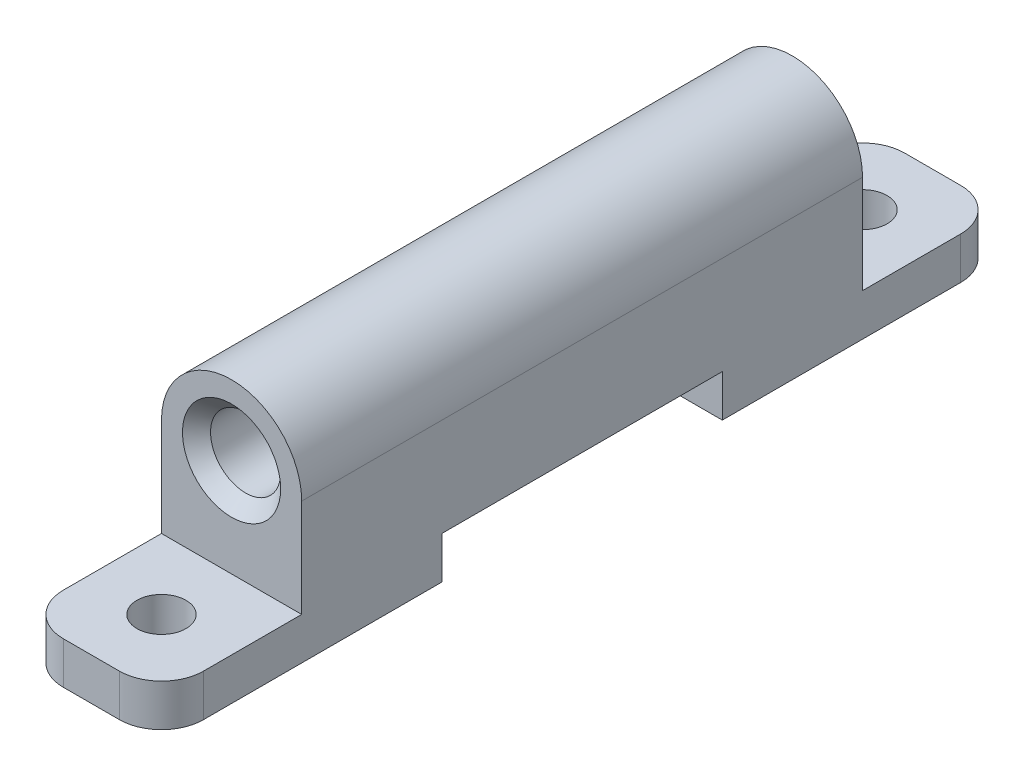
from build123d import *

# Parameters (mm, degrees)
SKETCH_1_R             = 2.5
EXTRUDE_1_DEPTH        = 20
SKETCH_2_W             = 10
SKETCH_2_H             = 20
EXTRUDE_2_DEPTH        = 3
SKETCH_3_R             = 1.75
CUT_EXTRUDE_1_DEPTH    = 4
FILLET_1_R             = 3
FILLET_1_OF_MIRROR_1_R = 3
CHAMFER_1_SIZE         = 1


with BuildPart() as part:
    # ｽｹｯﾁ1 → ﾎﾞｽ - 押し出し1 (new body, symmetric)
    with BuildSketch(Plane.XY):
        with BuildLine():
            Line((-5, 0), (5, 0))
            Line((5, 0), (5, 7))
            ThreePointArc((5, 7), (0, 12), (-5, 7))
            Line((-5, 7), (-5, 0))
        make_face()
        with Locations((0, 7)):
            Circle(SKETCH_1_R, mode=Mode.SUBTRACT)
    extrude(amount=EXTRUDE_1_DEPTH, both=True)

    # ｽｹｯﾁ2 → ﾎﾞｽ - 押し出し2 (add)
    with BuildSketch(Plane.XZ):
        with Locations((0, 20)):
            Rectangle(SKETCH_2_W, SKETCH_2_H)
    extrude_2 = extrude(amount=EXTRUDE_2_DEPTH)

    # ｽｹｯﾁ3 → ｶｯﾄ - 押し出し1 (cut, through all)
    with BuildSketch(Plane(origin=(0, 0, 0), x_dir=(1, 0, 0), z_dir=(0, 1, 0))):
        with Locations((0, -25)):
            Circle(SKETCH_3_R)
    cut_extrude_1 = extrude(amount=-CUT_EXTRUDE_1_DEPTH, mode=Mode.SUBTRACT)

    # ﾌｨﾚｯﾄ1
    fillet_1_edges = [part.edges().sort_by_distance(p)[0] for p in [
        (-5, -1.5, 30),
        (5, -1.5, 30),
    ]]
    fillet(fillet_1_edges, radius=FILLET_1_R)

    # ﾐﾗｰ1: ﾎﾞｽ - 押し出し2, ｶｯﾄ - 押し出し1 across plane
    add(extrude_2.mirror(Plane.XY))
    add(cut_extrude_1.mirror(Plane.XY), mode=Mode.SUBTRACT)

    # ﾌｨﾚｯﾄ1 of ﾐﾗｰ1
    fillet_1_of_mirror_1_edges = [part.edges().sort_by_distance(p)[0] for p in [
        (-5, -1.5, -30),
        (5, -1.5, -30),
    ]]
    fillet(fillet_1_of_mirror_1_edges, radius=FILLET_1_OF_MIRROR_1_R)

    # 面取り1
    chamfer_1_edges = [part.edges().sort_by_distance(p)[0] for p in [
        (-2.5, 7, -20),
        (-2.5, 7, 20),
    ]]
    chamfer(chamfer_1_edges, length=CHAMFER_1_SIZE)


solid = part.part
